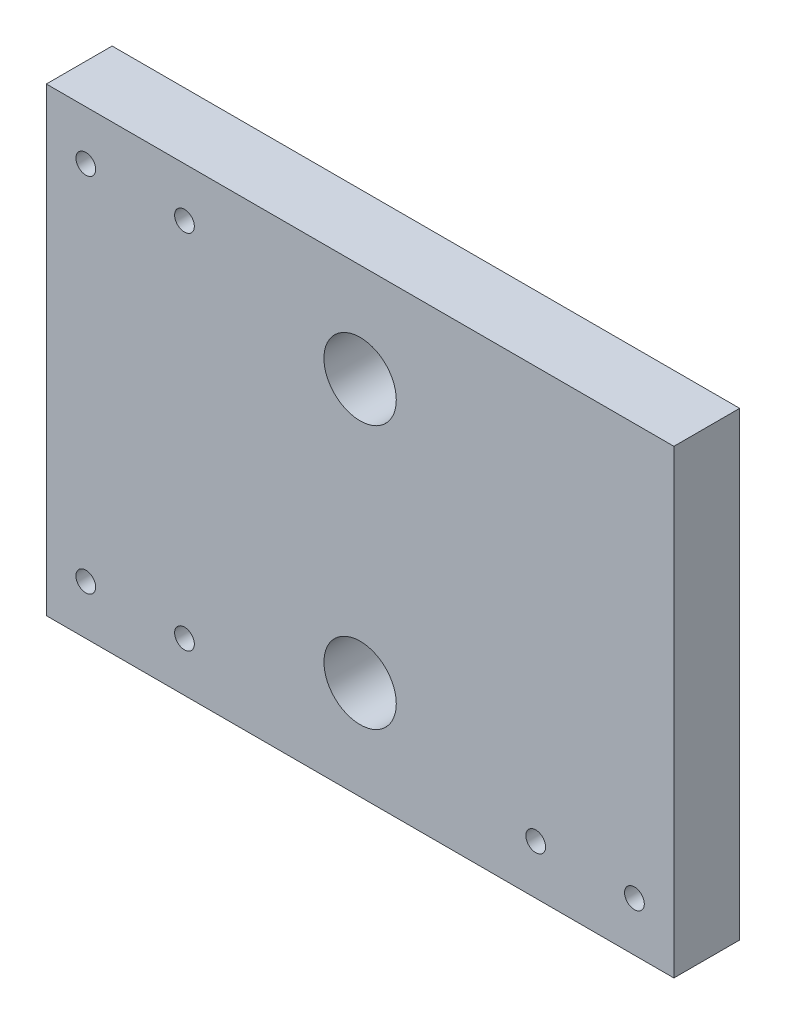
from build123d import *

# Parameters (mm, degrees)
SKETCH1_W           = 25
SKETCH1_H           = 70
SKETCH1_R           = 7.9375
BOSS_EXTRUDE1_DEPTH = 10
BOSS_EXTRUDE2_DEPTH = 10
SKETCH3_R           = 7.9375
SKETCH3_R_2         = 5.5
BOSS_EXTRUDE3_DEPTH = 8
SKETCH4_R           = 1.5
CUT_EXTRUDE1_DEPTH  = 11


with BuildPart() as part:
    # Sketch1 → Boss-Extrude1 (new body)
    with BuildSketch(Plane.XY):
        with Locations((0, 20)):
            Rectangle(SKETCH1_W, SKETCH1_H)
        with Locations((0, 40)):
            Circle(SKETCH1_R, mode=Mode.SUBTRACT)
        Circle(SKETCH1_R, mode=Mode.SUBTRACT)
    extrude(amount=BOSS_EXTRUDE1_DEPTH)

    # Sketch2 → Boss-Extrude2 (add)
    with BuildSketch(Plane.XY.offset(10)):
        Polygon((-47.7, 55), (-8.2, 55), (-8.2, 35.059438202), (-8.2, 32.231011077), (-8.2, 4.059438202), (-8.2, 1.231011077), (-8.2, -15), (-47.7, -15), align=None)
        Polygon((8.2, 35.059438202), (8.2, 32.231011077), (8.2, 4.059438202), (8.2, 1.231011077), (8.2, -15), (47.7, -15), (47.7, 55), (8.2, 55), align=None)
    extrude(amount=-BOSS_EXTRUDE2_DEPTH)

    # Sketch3 → Boss-Extrude3 (add)
    with BuildSketch(Plane.XY.offset(10)):
        with Locations((0, 40)):
            Circle(SKETCH3_R)
        with Locations((0, 40)):
            Circle(SKETCH3_R_2, mode=Mode.SUBTRACT)
        Circle(SKETCH3_R)
        Circle(SKETCH3_R_2, mode=Mode.SUBTRACT)
    extrude(amount=-BOSS_EXTRUDE3_DEPTH)

    # Sketch4 → Cut-Extrude1 (cut, through all)
    with BuildSketch(Plane(origin=(0, 0, 0), x_dir=(-1, 0, 0), z_dir=(0, 0, -1))):
        with Locations((26.7, 47.5)):
            Circle(SKETCH4_R)
        with Locations((41.7, 47.5)):
            Circle(SKETCH4_R)
        with Locations((-41.7, -7.5)):
            Circle(SKETCH4_R)
        with Locations((-26.7, -7.5)):
            Circle(SKETCH4_R)
        with Locations((41.7, -7.5)):
            Circle(SKETCH4_R)
        with Locations((26.7, -7.5)):
            Circle(SKETCH4_R)
    extrude(amount=-CUT_EXTRUDE1_DEPTH, mode=Mode.SUBTRACT)


solid = part.part
